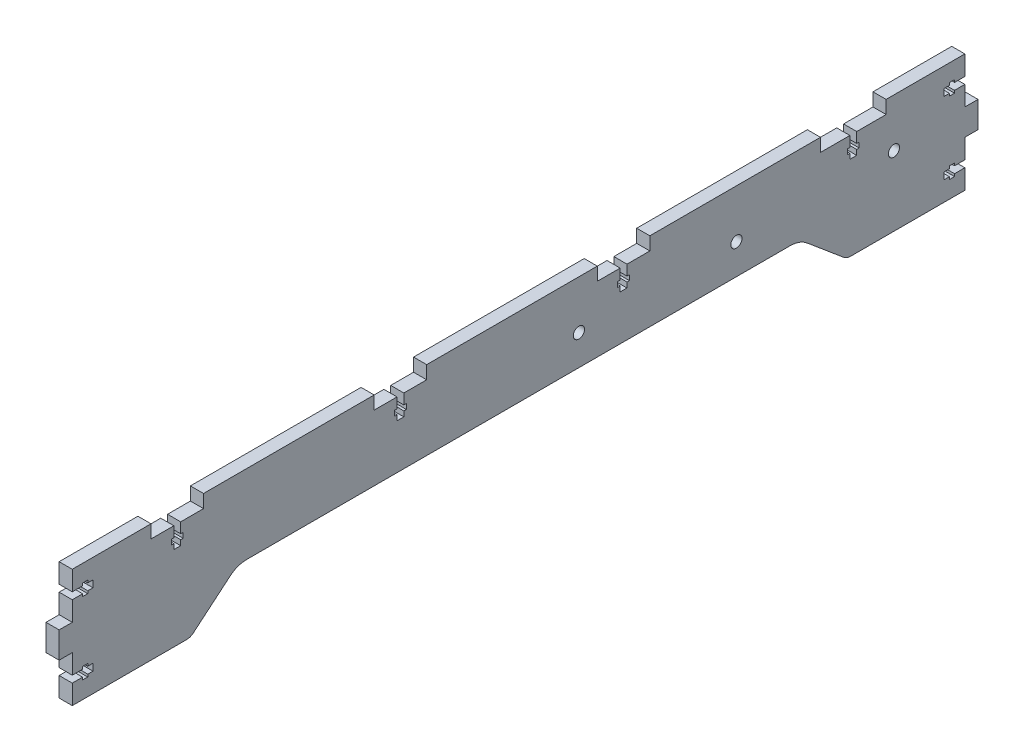
from build123d import *

# Parameters (mm, degrees)
SKETCH1_R           = 2.7
BOSS_EXTRUDE1_DEPTH = 6.35


with BuildPart() as part:
    # Sketch1 → Boss-Extrude1 (new body)
    with BuildSketch(Plane(origin=(0, 0, 0), x_dir=(0, 0, -1), z_dir=(1, 0, 0))):
        with BuildLine():
            Line((-44.45, 57.15), (-44.45, 50.8))
            Line((-44.45, 50.8), (-55.5, 50.8))
            Line((-55.5, 50.8), (-55.5, 45.8))
            Line((-55.5, 45.8), (-54.3, 45.8))
            Line((-54.3, 45.8), (-54.3, 43.3))
            Line((-54.3, 43.3), (-55.5, 43.3))
            Line((-55.5, 43.3), (-55.5, 40.8))
            Line((-55.5, 40.8), (-58.8, 40.8))
            Line((-58.8, 40.8), (-58.8, 43.3))
            Line((-58.8, 43.3), (-60, 43.3))
            Line((-60, 43.3), (-60, 45.8))
            Line((-60, 45.8), (-58.8, 45.8))
            Line((-58.8, 45.8), (-58.8, 50.8))
            Line((-58.8, 50.8), (-69.85, 50.8))
            Line((-69.85, 50.8), (-69.85, 57.15))
            Line((-69.85, 57.15), (-152.4, 57.15))
            Line((-152.4, 57.15), (-152.4, 50.8))
            Line((-152.4, 50.8), (-163.45, 50.8))
            Line((-163.45, 50.8), (-163.45, 45.8))
            Line((-163.45, 45.8), (-162.25, 45.8))
            Line((-162.25, 45.8), (-162.25, 43.3))
            Line((-162.25, 43.3), (-163.45, 43.3))
            Line((-163.45, 43.3), (-163.45, 40.8))
            Line((-163.45, 40.8), (-166.75, 40.8))
            Line((-166.75, 40.8), (-166.75, 43.3))
            Line((-166.75, 43.3), (-167.95, 43.3))
            Line((-167.95, 43.3), (-167.95, 45.8))
            Line((-167.95, 45.8), (-166.75, 45.8))
            Line((-166.75, 45.8), (-166.75, 50.8))
            Line((-166.75, 50.8), (-177.8, 50.8))
            Line((-177.8, 50.8), (-177.8, 57.15))
            Line((-177.8, 57.15), (-215.9, 57.15))
            Line((-215.9, 57.15), (-215.9, 47.6875))
            Line((-215.9, 47.6875), (-210.9, 47.6875))
            Line((-210.9, 47.6875), (-210.9, 48.8875))
            Line((-210.9, 48.8875), (-208.4, 48.8875))
            Line((-208.4, 48.8875), (-208.4, 47.6875))
            Line((-208.4, 47.6875), (-205.9, 47.6875))
            Line((-205.9, 47.6875), (-205.9, 44.3875))
            Line((-205.9, 44.3875), (-208.4, 44.3875))
            Line((-208.4, 44.3875), (-208.4, 43.1875))
            Line((-208.4, 43.1875), (-210.9, 43.1875))
            Line((-210.9, 43.1875), (-210.9, 44.3875))
            Line((-210.9, 44.3875), (-215.9, 44.3875))
            Line((-215.9, 44.3875), (-215.9, 34.925))
            Line((-215.9, 34.925), (-222.25, 34.925))
            Line((-222.25, 34.925), (-222.25, 22.225))
            Line((-222.25, 22.225), (-215.9, 22.225))
            Line((-215.9, 22.225), (-215.9, 12.7625))
            Line((-215.9, 12.7625), (-210.9, 12.7625))
            Line((-210.9, 12.7625), (-210.9, 13.9625))
            Line((-210.9, 13.9625), (-208.4, 13.9625))
            Line((-208.4, 13.9625), (-208.4, 12.7625))
            Line((-208.4, 12.7625), (-205.9, 12.7625))
            Line((-205.9, 12.7625), (-205.9, 9.4625))
            Line((-205.9, 9.4625), (-208.4, 9.4625))
            Line((-208.4, 9.4625), (-208.4, 8.2625))
            Line((-208.4, 8.2625), (-210.9, 8.2625))
            Line((-210.9, 8.2625), (-210.9, 9.4625))
            Line((-210.9, 9.4625), (-215.9, 9.4625))
            Line((-215.9, 9.4625), (-215.9, 0))
            Line((-215.9, 0), (-160.59896879, 0))
            ThreePointArc((-160.59896879, 0), (-158.861506462, 0.306361486), (-157.333607733, 1.188494229))
            Line((-157.333607733, 1.188494229), (-139.588074729, 16.078764428))
            ThreePointArc((-139.588074729, 16.078764428), (-135.768327906, 18.284096284), (-131.424672086, 19.05))
            Line((-131.424672086, 19.05), (131.424672086, 19.05))
            ThreePointArc((131.424672086, 19.05), (135.768327906, 18.284096284), (139.588074729, 16.078764428))
            Line((139.588074729, 16.078764428), (157.333607733, 1.188494229))
            ThreePointArc((157.333607733, 1.188494229), (158.861506462, 0.306361486), (160.59896879, 0))
            Line((160.59896879, 0), (215.9, 0))
            Line((215.9, 0), (215.9, 9.4625))
            Line((215.9, 9.4625), (210.9, 9.4625))
            Line((210.9, 9.4625), (210.9, 8.2625))
            Line((210.9, 8.2625), (208.4, 8.2625))
            Line((208.4, 8.2625), (208.4, 9.4625))
            Line((208.4, 9.4625), (205.9, 9.4625))
            Line((205.9, 9.4625), (205.9, 12.7625))
            Line((205.9, 12.7625), (208.4, 12.7625))
            Line((208.4, 12.7625), (208.4, 13.9625))
            Line((208.4, 13.9625), (210.9, 13.9625))
            Line((210.9, 13.9625), (210.9, 12.7625))
            Line((210.9, 12.7625), (215.9, 12.7625))
            Line((215.9, 12.7625), (215.9, 22.225))
            Line((215.9, 22.225), (222.25, 22.225))
            Line((222.25, 22.225), (222.25, 34.925))
            Line((222.25, 34.925), (215.9, 34.925))
            Line((215.9, 34.925), (215.9, 44.3875))
            Line((215.9, 44.3875), (210.9, 44.3875))
            Line((210.9, 44.3875), (210.9, 43.1875))
            Line((210.9, 43.1875), (208.4, 43.1875))
            Line((208.4, 43.1875), (208.4, 44.3875))
            Line((208.4, 44.3875), (205.9, 44.3875))
            Line((205.9, 44.3875), (205.9, 47.6875))
            Line((205.9, 47.6875), (208.4, 47.6875))
            Line((208.4, 47.6875), (208.4, 48.8875))
            Line((208.4, 48.8875), (210.9, 48.8875))
            Line((210.9, 48.8875), (210.9, 47.6875))
            Line((210.9, 47.6875), (215.9, 47.6875))
            Line((215.9, 47.6875), (215.9, 57.15))
            Line((215.9, 57.15), (177.8, 57.15))
            Line((177.8, 57.15), (177.8, 50.8))
            Line((177.8, 50.8), (163.575, 50.8))
            Line((163.575, 50.8), (163.575, 45.8))
            Line((163.575, 45.8), (164.775, 45.8))
            Line((164.775, 45.8), (164.775, 43.3))
            Line((164.775, 43.3), (163.575, 43.3))
            Line((163.575, 43.3), (163.575, 40.8))
            Line((163.575, 40.8), (160.275, 40.8))
            Line((160.275, 40.8), (160.275, 43.3))
            Line((160.275, 43.3), (159.075, 43.3))
            Line((159.075, 43.3), (159.075, 45.8))
            Line((159.075, 45.8), (160.275, 45.8))
            Line((160.275, 45.8), (160.275, 50.8))
            Line((160.275, 50.8), (146.05, 50.8))
            Line((146.05, 50.8), (146.05, 57.15))
            Line((146.05, 57.15), (63.5, 57.15))
            Line((63.5, 57.15), (63.5, 50.8))
            Line((63.5, 50.8), (52.45, 50.8))
            Line((52.45, 50.8), (52.45, 45.8))
            Line((52.45, 45.8), (53.65, 45.8))
            Line((53.65, 45.8), (53.65, 43.3))
            Line((53.65, 43.3), (52.45, 43.3))
            Line((52.45, 43.3), (52.45, 40.8))
            Line((52.45, 40.8), (49.15, 40.8))
            Line((49.15, 40.8), (49.15, 43.3))
            Line((49.15, 43.3), (47.95, 43.3))
            Line((47.95, 43.3), (47.95, 45.8))
            Line((47.95, 45.8), (49.15, 45.8))
            Line((49.15, 45.8), (49.15, 50.8))
            Line((49.15, 50.8), (38.1, 50.8))
            Line((38.1, 50.8), (38.1, 57.15))
            Line((38.1, 57.15), (-44.45, 57.15))
        make_face()
        with Locations((105.388301448, 33.74898)):
            Circle(SKETCH1_R, mode=Mode.SUBTRACT)
        with Locations((29.188301448, 33.74898)):
            Circle(SKETCH1_R, mode=Mode.SUBTRACT)
        with Locations((181.588301448, 33.74898)):
            Circle(SKETCH1_R, mode=Mode.SUBTRACT)
    extrude(amount=-BOSS_EXTRUDE1_DEPTH)


solid = part.part
